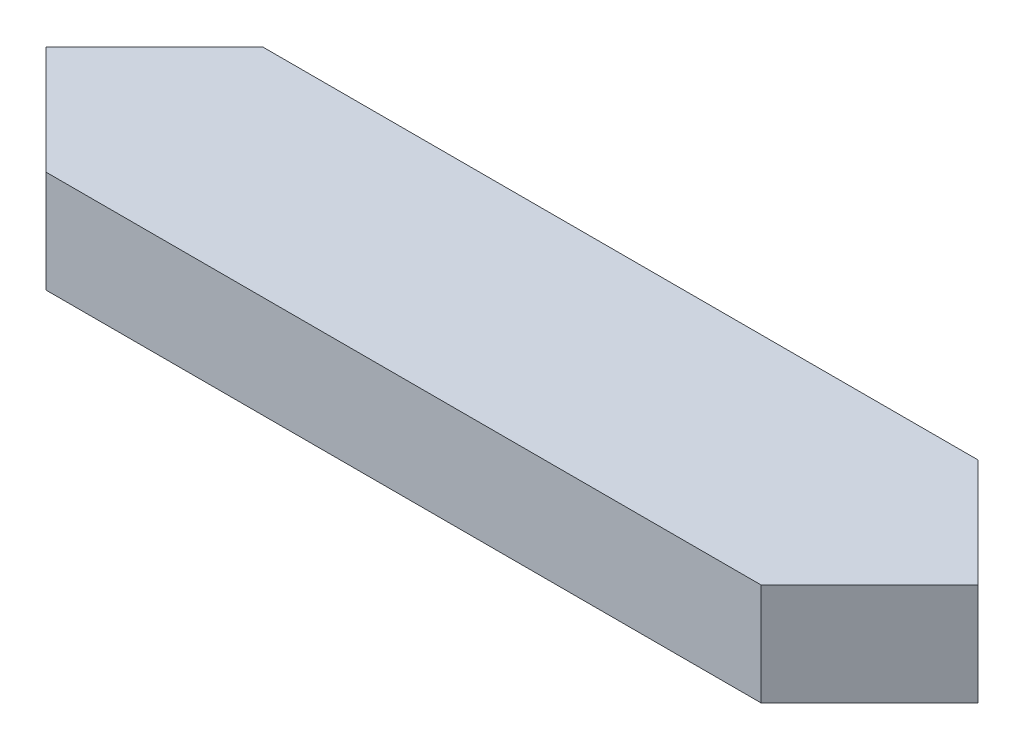
from build123d import *

# Parameters (mm, degrees)
BOSS_EXTRUDE1_DEPTH = 0.254


with BuildPart() as part:
    # Sketch1 → Boss-Extrude1 (new body)
    with BuildSketch(Plane(origin=(0, 0, 0), x_dir=(1, 0, 0), z_dir=(0, 1, 0))):
        Polygon((0, 0), (0.269407684, 0.269407684), (2.047407684, 0.269407684), (2.316815367, 0), (2.047407684, -0.269407684), (0.269407684, -0.269407684), align=None)
    extrude(amount=BOSS_EXTRUDE1_DEPTH)


solid = part.part
